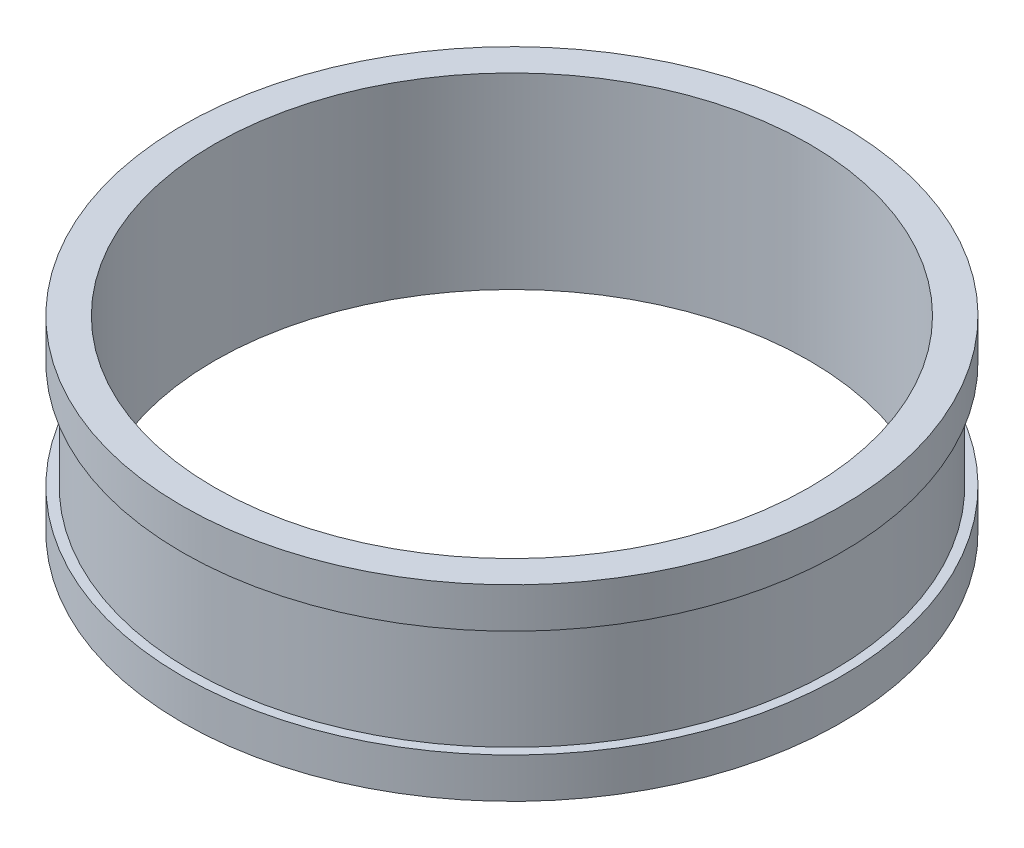
from build123d import *

# Parameters (mm, degrees)
SKETCH1_R           = 12.3
SKETCH1_R_2         = 11.1
BOSS_EXTRUDE1_DEPTH = 7
SKETCH2_W           = 0.35
SKETCH2_H           = 4


with BuildPart() as part:
    # Sketch1 → Boss-Extrude1 (new body)
    with BuildSketch(Plane(origin=(0, 0, 0), x_dir=(1, 0, 0), z_dir=(0, 1, 0))):
        Circle(SKETCH1_R)
        Circle(SKETCH1_R_2, mode=Mode.SUBTRACT)
    extrude(amount=BOSS_EXTRUDE1_DEPTH)

    # Sketch2 → Cut-Revolve1 (revolve, cut)
    with BuildSketch(Plane.XY):
        with Locations((-12.125, 3.5)):
            Rectangle(SKETCH2_W, SKETCH2_H)
    revolve(axis=Axis((0, 7, 0), (0, -1, 0)), mode=Mode.SUBTRACT)


solid = part.part
